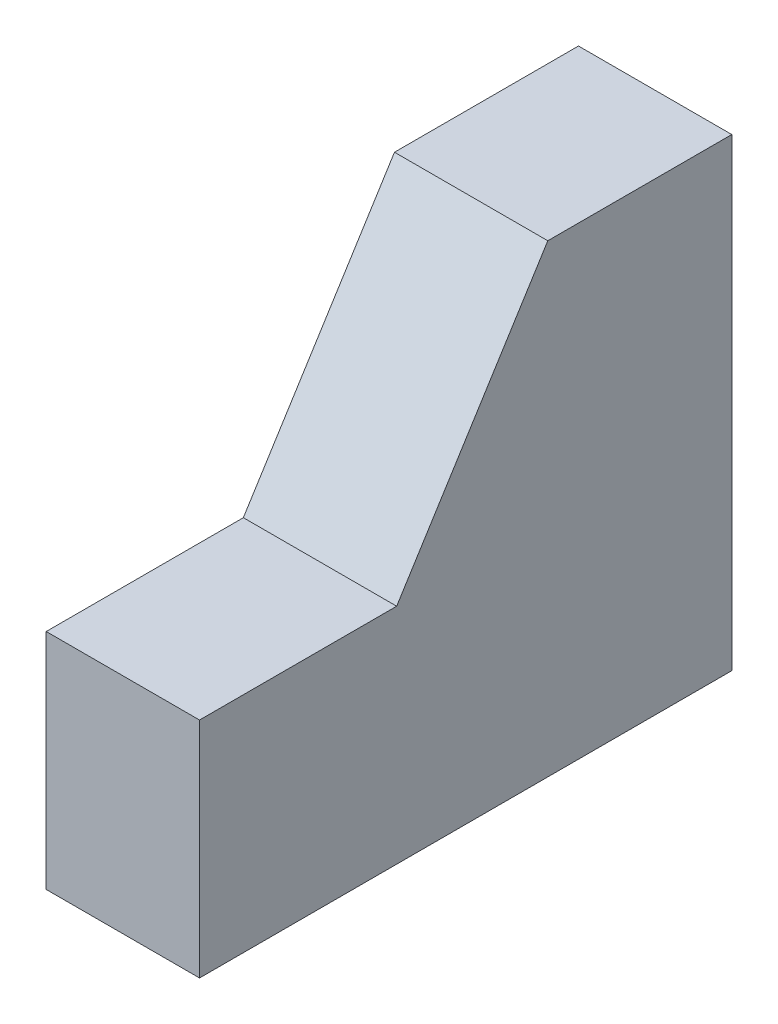
from build123d import *

# Parameters (mm, degrees)
BOSS_EXTRUDE1_DEPTH = 7
SKETCH2_R           = 1.45
CUT_EXTRUDE1_DEPTH  = 7.5
SKETCH3_R           = 1.45
CUT_EXTRUDE2_DEPTH  = 7.5


with BuildPart() as part:
    # Sketch1 → Boss-Extrude1 (new body)
    with BuildSketch(Plane(origin=(0, 0, 0), x_dir=(0, 0, -1), z_dir=(1, 0, 0))):
        Polygon((0, 0), (0, 10.2), (9, 10.2), (15.9, 21.2), (24.3, 21.2), (24.3, 0), align=None)
    extrude(amount=BOSS_EXTRUDE1_DEPTH)

    # Sketch2 → Cut-Extrude1 (cut)
    with BuildSketch(Plane.XZ):
        with Locations((3.5, -5.35)):
            Circle(SKETCH2_R)
        with Locations((3.5, -14.75)):
            Circle(SKETCH2_R)
    extrude(amount=-CUT_EXTRUDE1_DEPTH, mode=Mode.SUBTRACT)

    # Sketch3 → Cut-Extrude2 (cut)
    with BuildSketch(Plane(origin=(0, 0, -24.3), x_dir=(-1, 0, 0), z_dir=(0, 0, -1))):
        with Locations((-3.5, 15.75)):
            Circle(SKETCH3_R)
        with Locations((-3.5, 5.35)):
            Circle(SKETCH3_R)
    extrude(amount=-CUT_EXTRUDE2_DEPTH, mode=Mode.SUBTRACT)


solid = part.part
